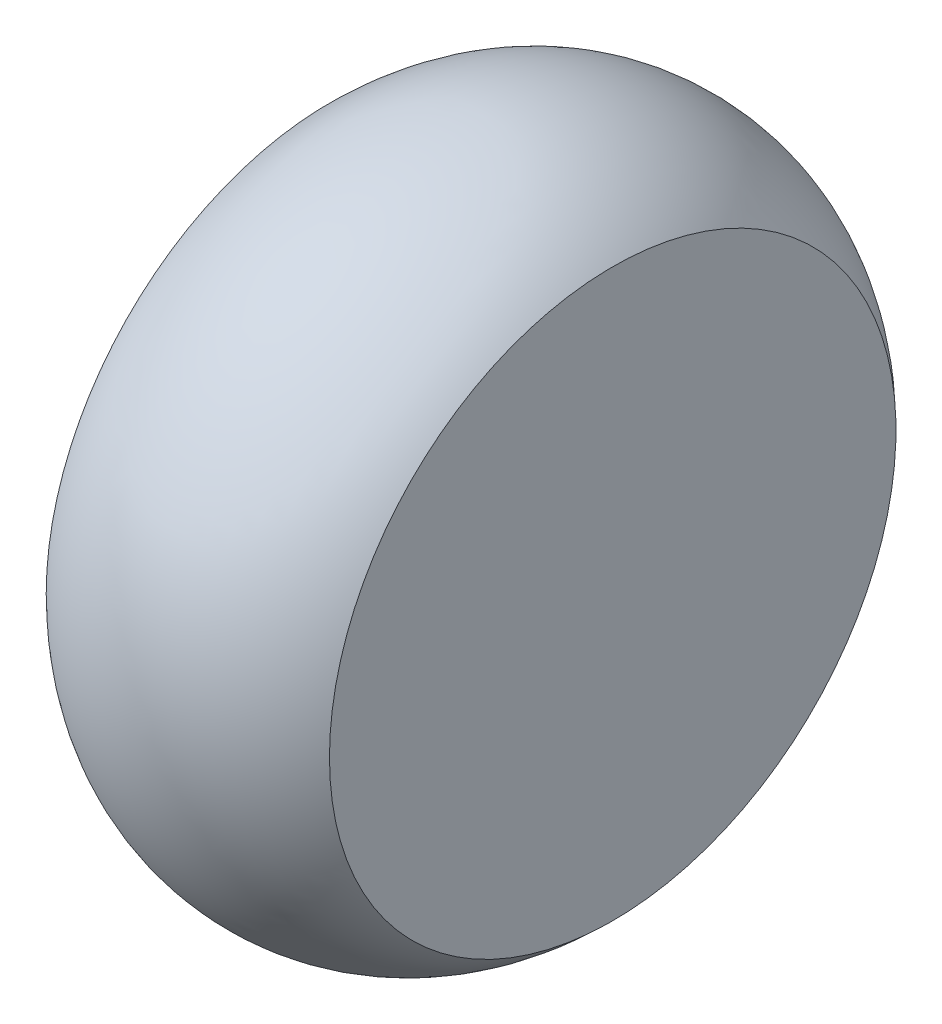
from build123d import *

# Parameters (mm, degrees)
SKETCH2_R           = 40
SKETCH2_R_2         = 23.258830185
BOSS_EXTRUDE1_DEPTH = 20


with BuildPart() as part:
    # Sketch2 → Boss-Extrude1 (new, symmetric)
    with BuildSketch(Plane(origin=(0, 0, 0), x_dir=(0, 0, -1), z_dir=(1, 0, 0))):
        Circle(SKETCH2_R)
        Circle(SKETCH2_R_2, mode=Mode.SUBTRACT)
        Circle(SKETCH2_R_2)
    extrude(amount=BOSS_EXTRUDE1_DEPTH, both=True)

    # Sketch3 → Revolve1 (revolve)
    with BuildSketch(Plane.XY, mode=Mode.PRIVATE) as revolve1_sk:
        with BuildLine():
            Line((-20, 40), (20, 40))
            ThreePointArc((20, 40), (0, 48.284271247), (-20, 40))
        make_face()
    revolve(revolve1_sk.sketch.rotate(Axis((0, 0, 0), (1, 0, 0)), 90), axis=Axis((0, 0, 0), (1, 0, 0)))


solid = part.part
